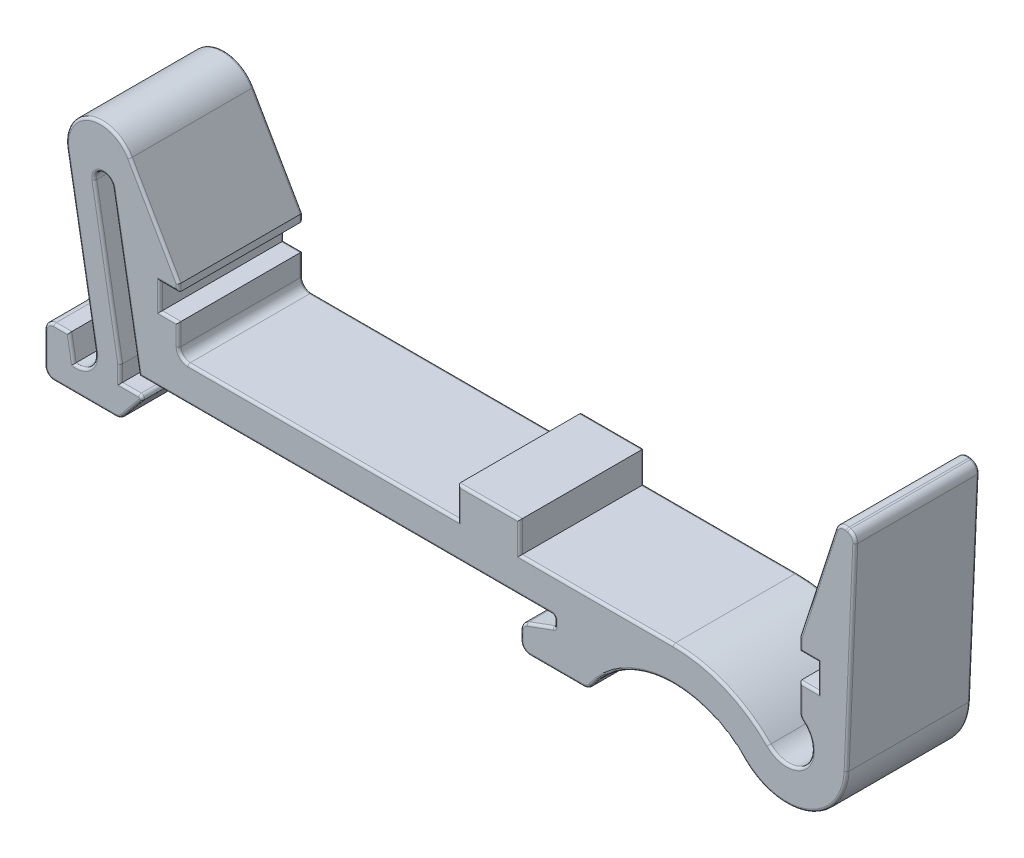
from build123d import *

# Parameters (mm, degrees)
BOSS_EXTRUDE1_DEPTH = 10
SKETCH2_W           = 5
SKETCH2_H           = 2.50000041
BOSS_EXTRUDE2_DEPTH = 10
FILLET1_R           = 0.2


with BuildPart() as part:
    # Sketch1 → Boss-Extrude1 (new body)
    with BuildSketch(Plane.XY):
        with BuildLine():
            Line((-4.296971951, 0.200000009), (-5.546971806, 0.200000009))
            ThreePointArc((-5.546971806, 0.200000009), (-6.077301897, -0.019669907), (-6.296971813, -0.549999997))
            Line((-6.296971813, -0.549999997), (-6.296971813, -3.049999941))
            ThreePointArc((-6.296971813, -3.049999941), (-6.077301863, -3.580330114), (-5.54697169, -3.800000064))
            Line((-5.54697169, -3.800000064), (-0.576388382, -3.800000064))
            ThreePointArc((-0.576388382, -3.800000064), (-0.255560204, -3.727915451), (0.003596569, -3.525518122))
            Line((0.003596569, -3.525518122), (1.493328299, -1.708505965))
            ThreePointArc((1.493328299, -1.708505965), (1.525971756, -1.443057251), (1.299999991, -1.300000004))
            Line((1.299999991, -1.300000004), (-0.200000009, -1.300000004))
            Line((-0.200000009, -1.300000004), (-0.200000009, 0))
            Line((-0.200000009, 0), (-2.283778274, 11.817692779))
            ThreePointArc((-2.283778274, 11.817692779), (-1.675408541, 12.686534821), (-0.806566503, 12.078165082))
            Line((-0.806566503, 12.078165082), (1.323139877, 0))
            Line((1.323139877, 0), (34.550001657, 0))
            ThreePointArc((34.550001657, 0), (34.726778361, -0.073223308), (34.800001669, -0.250000012))
            Line((34.800001669, -0.250000012), (34.800001669, -0.624949703))
            ThreePointArc((34.800001669, -0.624949703), (34.754789965, -0.768342863), (34.635507751, -0.859871274))
            Line((34.635507751, -0.859871274), (32.543484811, -1.621304491))
            ThreePointArc((32.543484811, -1.621304491), (32.185635823, -1.895891523), (32.049999821, -2.326073823))
            Line((32.049999821, -2.326073823), (32.049999821, -3.050917992))
            ThreePointArc((32.049999821, -3.050917992), (32.269669771, -3.581248165), (32.799999944, -3.800918115))
            Line((32.799999944, -3.800918115), (37.094996393, -3.800918115))
            ThreePointArc((37.094996393, -3.800918115), (37.443571915, -3.714992841), (37.712276995, -3.476905404))
            ThreePointArc((37.712276995, -3.476905404), (43.619050379, -0.032015959), (50.043494523, -2.373757306))
            ThreePointArc((50.043494523, -2.373757306), (55.223050481, -3.474080996), (58.309068328, 0.828825695))
            Line((58.309068328, 0.828825695), (59.011095117, 17.069915141))
            ThreePointArc((59.011095117, 17.069915141), (58.866532799, 17.545918646), (58.455911547, 17.826752737))
            Line((58.455911547, 17.826752737), (58.311756553, 17.865380473))
            ThreePointArc((58.311756553, 17.865380473), (57.759750272, 17.799755092), (57.404965978, 17.371799802))
            Line((57.404965978, 17.371799802), (54.499999702, 8.366627088))
            Line((54.499999702, 8.366627088), (54.499999702, 7.399995259))
            Line((54.499999702, 7.399995259), (55.999999017, 7.399995259))
            Line((55.999999017, 7.399995259), (55.999999017, 5.30000031))
            Line((55.999999017, 5.30000031), (54.499999702, 5.30000031))
            Line((54.499999702, 5.30000031), (54.499999702, 3.188544419))
            ThreePointArc((54.499999702, 3.188544419), (54.571562448, 2.868821121), (54.772594094, 2.610111842))
            ThreePointArc((54.772594094, 2.610111842), (54.981559607, -0.335608674), (52.029130131, -0.399609737))
            ThreePointArc((52.029130131, -0.399609737), (48.502075904, 1.968208055), (44.336167246, 2.7999999))
            Line((44.336167246, 2.7999999), (5.249999929, 2.7999999))
            ThreePointArc((5.249999929, 2.7999999), (4.719669756, 3.01966985), (4.499999806, 3.550000023))
            Line((4.499999806, 3.550000023), (4.499999806, 5.30000031))
            Line((4.499999806, 5.30000031), (3.000000026, 5.30000031))
            Line((3.000000026, 5.30000031), (3.000000026, 7.400000002))
            Line((3.000000026, 7.400000002), (4.499999806, 7.400000002))
            Line((4.499999806, 7.400000002), (4.499999806, 7.973031965))
            Line((4.499999806, 7.973031965), (0.578576978, 14.795537856))
            ThreePointArc((0.578576978, 14.795537856), (-2.743703611, 16.010202929), (-4.513865919, 12.947608448))
            Line((-4.513865919, 12.947608448), (-2.230853096, 0))
            ThreePointArc((-2.230853096, 0), (-2.633070065, -1.332664481), (-3.94431781, -1.799999969))
            Line((-3.94431781, -1.799999969), (-4.296971951, 0.200000009))
        make_face()
    extrude(amount=BOSS_EXTRUDE1_DEPTH)

    # Sketch2 → Boss-Extrude2 (add)
    with BuildSketch(Plane.XY):
        with Locations((29.499999521, 4.050000105)):
            Rectangle(SKETCH2_W, SKETCH2_H)
    extrude(amount=BOSS_EXTRUDE2_DEPTH)

    # Fillet1
    fillet1_edges = [part.edges().sort_by_distance(p)[0] for p in [
        (-4.921971879, 0.200000009, 0),
        (-6.077301897, -0.019669907, 0),
        (-6.296971813, -1.799999969, 0),
        (-6.077301863, -3.580330114, 0),
        (-3.061680036, -3.800000064, 0),
        (-0.255560204, -3.727915451, 0),
        (0.748462434, -2.617012044, 0),
        (1.525971756, -1.443057251, 0),
        (0.549999991, -1.300000004, 0),
        (-0.200000009, -0.650000002, 0),
        (-1.241889142, 5.90884639, 0),
        (-1.675408541, 12.686534821, 0),
        (0.258286687, 6.039082541, 0),
        (17.936570767, 0, 0),
        (34.726778361, -0.073223308, 0),
        (34.800001669, -0.437474857, 0),
        (34.754789965, -0.768342863, 0),
        (33.589496281, -1.240587883, 0),
        (32.185635823, -1.895891523, 0),
        (32.049999821, -2.688495908, 0),
        (32.269669771, -3.581248165, 0),
        (34.947498168, -3.800918115, 0),
        (37.443571915, -3.714992841, 0),
        (43.619050379, -0.032015959, 0),
        (55.223050481, -3.474080996, 0),
        (58.660081723, 8.949370418, 0),
        (58.866532799, 17.545918646, 0),
        (58.38383405, 17.846066605, 0),
        (57.759750272, 17.799755092, 0),
        (55.95248284, 12.869213445, 0),
        (54.499999702, 7.883311173, 0),
        (55.249999359, 7.399995259, 0),
        (55.999999017, 6.349997785, 0),
        (55.249999359, 5.30000031, 0),
        (54.499999702, 4.244272364, 0),
        (54.571562448, 2.868821121, 0),
        (54.981559607, -0.335608674, 0),
        (48.502075904, 1.968208055, 0),
        (16.124999725, 2.7999999, 0),
        (38.168083384, 2.7999999, 0),
        (4.719669756, 3.01966985, 0),
        (4.499999806, 4.425000167, 0),
        (3.749999916, 5.30000031, 0),
        (3.000000026, 6.350000156, 0),
        (3.749999916, 7.400000002, 0),
        (4.499999806, 7.686515984, 0),
        (2.539288392, 11.384284911, 0),
        (-2.743703611, 16.010202929, 0),
        (-3.372359508, 6.473804224, 0),
        (-2.633070065, -1.332664481, 0),
        (-4.12064488, -0.79999998, 0),
        (-2.633070065, -1.332664481, 10),
        (-3.372359508, 6.473804224, 10),
        (-2.743703611, 16.010202929, 10),
        (2.539288392, 11.384284911, 10),
        (4.499999806, 7.686515984, 10),
        (3.749999916, 7.400000002, 10),
        (3.000000026, 6.350000156, 10),
        (3.749999916, 5.30000031, 10),
        (4.499999806, 4.425000167, 10),
        (4.719669756, 3.01966985, 10),
        (38.168083384, 2.7999999, 10),
        (16.124999725, 2.7999999, 10),
        (48.502075904, 1.968208055, 10),
        (54.981559607, -0.335608674, 10),
        (54.571562448, 2.868821121, 10),
        (54.499999702, 4.244272364, 10),
        (55.249999359, 5.30000031, 10),
        (55.999999017, 6.349997785, 10),
        (55.249999359, 7.399995259, 10),
        (54.499999702, 7.883311173, 10),
        (55.95248284, 12.869213445, 10),
        (57.759750272, 17.799755092, 10),
        (58.38383405, 17.846066605, 10),
        (58.866532799, 17.545918646, 10),
        (58.660081723, 8.949370418, 10),
        (55.223050481, -3.474080996, 10),
        (43.619050379, -0.032015959, 10),
        (37.443571915, -3.714992841, 10),
        (34.947498168, -3.800918115, 10),
        (32.269669771, -3.581248165, 10),
        (32.049999821, -2.688495908, 10),
        (32.185635823, -1.895891523, 10),
        (33.589496281, -1.240587883, 10),
        (34.754789965, -0.768342863, 10),
        (34.800001669, -0.437474857, 10),
        (34.726778361, -0.073223308, 10),
        (17.936570767, 0, 10),
        (0.258286687, 6.039082541, 10),
        (-1.675408541, 12.686534821, 10),
        (-1.241889142, 5.90884639, 10),
        (-0.200000009, -0.650000002, 10),
        (0.549999991, -1.300000004, 10),
        (1.525971756, -1.443057251, 10),
        (0.748462434, -2.617012044, 10),
        (-0.255560204, -3.727915451, 10),
        (-3.061680036, -3.800000064, 10),
        (-6.077301863, -3.580330114, 10),
        (-6.296971813, -1.799999969, 10),
        (-6.077301897, -0.019669907, 10),
        (-4.921971879, 0.200000009, 10),
        (-4.12064488, -0.79999998, 10),
        (31.999999521, 4.050000105, 10),
        (31.999999521, 4.050000105, 0),
        (29.499999521, 5.30000031, 10),
        (29.499999521, 5.30000031, 0),
        (26.999999521, 4.050000105, 10),
        (26.999999521, 4.050000105, 0),
    ]]
    fillet(fillet1_edges, radius=FILLET1_R)


solid = part.part
